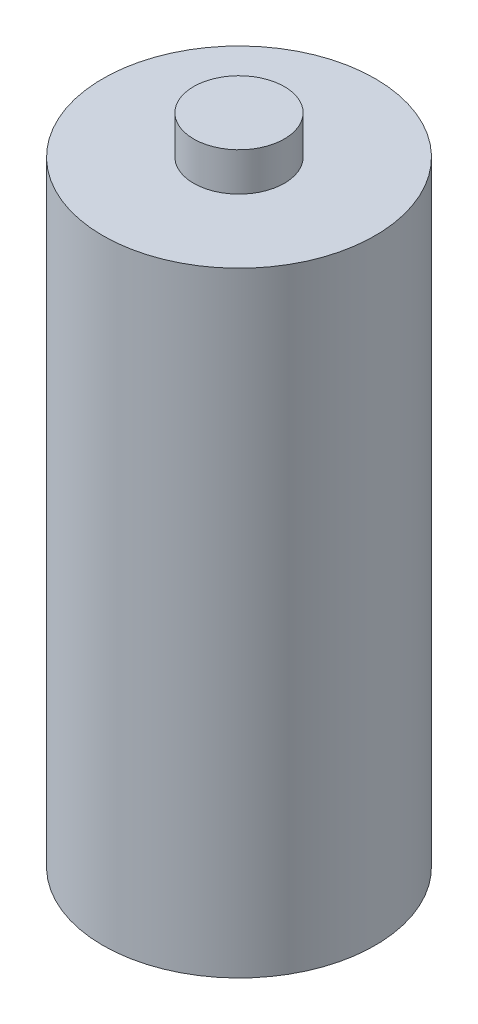
from build123d import *

# Parameters (mm, degrees)
SKETCH1_R           = 7.5
BOSS_EXTRUDE2_DEPTH = 57.15
SKETCH1_3_R         = 22.5
BOSS_EXTRUDE3_DEPTH = 50.8


with BuildPart() as part:
    # Sketch1 → Boss-Extrude2 (new, symmetric)
    with BuildSketch(Plane(origin=(0, 0, 0), x_dir=(1, 0, 0), z_dir=(0, 1, 0))):
        Circle(SKETCH1_R)
    extrude(amount=BOSS_EXTRUDE2_DEPTH, both=True)

    # Sketch1_3 → Boss-Extrude3 (add, symmetric)
    with BuildSketch(Plane(origin=(0, 0, 0), x_dir=(1, 0, 0), z_dir=(0, 1, 0))):
        Circle(SKETCH1_3_R)
    extrude(amount=BOSS_EXTRUDE3_DEPTH, both=True)


solid = part.part
